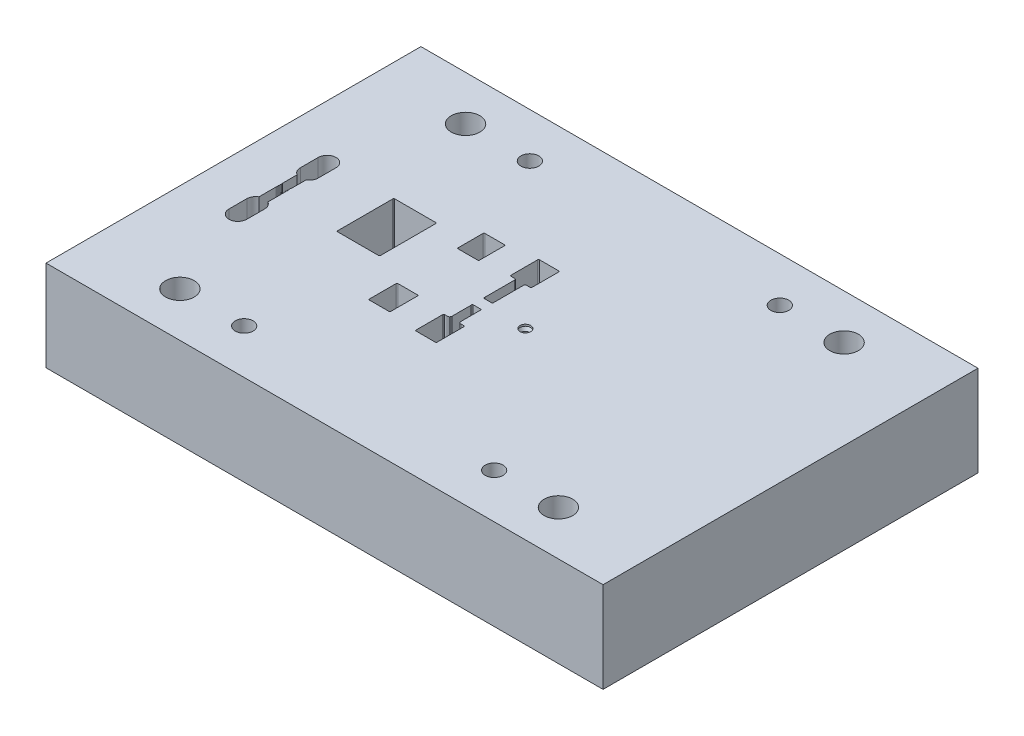
from build123d import *

# Parameters (mm, degrees)
SKETCH1_W             = 156
SKETCH1_H             = 25.4
EXTRUDE1_DEPTH        = 52.5
M6_TAPPED_HOLE1_D     = 5
M6_TAPPED_HOLE1_DEPTH = 15
M6_TAPPED_HOLE1_TIP   = 1.502151548
HOLE1_D               = 8
CUT_EXTRUDE1_DEPTH    = 26.4
CUT_EXTRUDE2_DEPTH    = 8
FILLET2_R             = 0.25
HOLE3_D               = 10
HOLE3_DEPTH           = 5


with BuildPart() as part:
    # Sketch1 → Extrude1 (new body, symmetric)
    with BuildSketch(Plane.XY):
        with Locations((0, 12.7)):
            Rectangle(SKETCH1_W, SKETCH1_H)
    extrude(amount=EXTRUDE1_DEPTH, both=True)

    # M6 Tapped Hole1
    with Locations(Plane(origin=(0, 25.4, 0), x_dir=(-1, 0, 0), z_dir=(0, 1, 0))):
        with Locations((35, -40), (-35, -40), (-35, 40), (35, 40)):
            Hole(M6_TAPPED_HOLE1_D / 2, depth=M6_TAPPED_HOLE1_DEPTH)
            with Locations((0, 0, -(M6_TAPPED_HOLE1_DEPTH + M6_TAPPED_HOLE1_TIP / 2))):  # 118° drill point
                Cone(0, M6_TAPPED_HOLE1_D / 2, M6_TAPPED_HOLE1_TIP, mode=Mode.SUBTRACT)

    # Hole1 (through all)
    with Locations(Plane(origin=(0, 25.4, 0), x_dir=(-1, 0, 0), z_dir=(0, 1, 0))):
        with Locations((53, -40), (53, 40), (-53, 40), (-53, -40)):
            Hole(HOLE1_D / 2)

    # Sketch6 → Cut-Extrude1 (cut, through all)
    with BuildSketch(Plane(origin=(0, 25.4, 0), x_dir=(1, 0, 0), z_dir=(0, 1, 0))):
        with BuildLine():
            Line((-61.75, -6.788439774), (-61.515076845, -7.433885839))
            ThreePointArc((-61.515076845, -7.433885839), (-61.545211989, -7.662784984), (-61.75, -7.769390874))
            Line((-61.75, -7.769390874), (-64.25, -7.769390874))
            ThreePointArc((-64.25, -7.769390874), (-64.454788011, -7.662784984), (-64.484923155, -7.433885839))
            Line((-64.484923155, -7.433885839), (-64.25, -6.788439774))
            Line((-64.25, -6.788439774), (-64.25, -1.795359581))
            ThreePointArc((-64.25, -1.795359581), (-64.237170825, -1.716302639), (-64.2, -1.645359581))
            ThreePointArc((-64.2, -1.645359581), (-64.15, -1.495359581), (-64.2, -1.345359581))
            ThreePointArc((-64.2, -1.345359581), (-64.25, -1.195359581), (-64.2, -1.045359581))
            ThreePointArc((-64.2, -1.045359581), (-64.15, -0.895359581), (-64.2, -0.745359581))
            ThreePointArc((-64.2, -0.745359581), (-64.25, -0.595359581), (-64.2, -0.445359581))
            ThreePointArc((-64.2, -0.445359581), (-64.15, -0.295359581), (-64.2, -0.145359581))
            ThreePointArc((-64.2, -0.145359581), (-64.237170825, -0.074416522), (-64.25, 0.004640419))
            Line((-64.25, 0.004640419), (-64.25, 4.249658026))
            Line((-64.25, 4.249658026), (-64.484923155, 4.89510409))
            ThreePointArc((-64.484923155, 4.89510409), (-64.454788011, 5.124003235), (-64.25, 5.230609126))
            Line((-64.25, 5.230609126), (-61.75, 5.230609126))
            ThreePointArc((-61.75, 5.230609126), (-61.545211989, 5.124003235), (-61.515076845, 4.89510409))
            Line((-61.515076845, 4.89510409), (-61.75, 4.249658026))
            Line((-61.75, 4.249658026), (-61.75, 0.004640419))
            ThreePointArc((-61.75, 0.004640419), (-61.762829175, -0.074416522), (-61.8, -0.145359581))
            ThreePointArc((-61.8, -0.145359581), (-61.85, -0.295359581), (-61.8, -0.445359581))
            ThreePointArc((-61.8, -0.445359581), (-61.75, -0.595359581), (-61.8, -0.745359581))
            ThreePointArc((-61.8, -0.745359581), (-61.85, -0.895359581), (-61.8, -1.045359581))
            ThreePointArc((-61.8, -1.045359581), (-61.75, -1.195359581), (-61.8, -1.345359581))
            ThreePointArc((-61.8, -1.345359581), (-61.85, -1.495359581), (-61.8, -1.645359581))
            ThreePointArc((-61.8, -1.645359581), (-61.762829175, -1.716302639), (-61.75, -1.795359581))
            Line((-61.75, -1.795359581), (-61.75, -6.788439774))
        make_face()
        with BuildLine():
            Line((-18.25, -8.195359581), (-23.75, -8.195359581))
            ThreePointArc((-23.75, -8.195359581), (-23.926776695, -8.268582886), (-24, -8.445359581))
            Line((-24, -8.445359581), (-24, -15.945359581))
            ThreePointArc((-24, -15.945359581), (-23.926776695, -16.122136276), (-23.75, -16.195359581))
            Line((-23.75, -16.195359581), (-18.25, -16.195359581))
            ThreePointArc((-18.25, -16.195359581), (-18.073223305, -16.122136276), (-18, -15.945359581))
            Line((-18, -15.945359581), (-18, -8.445359581))
            ThreePointArc((-18, -8.445359581), (-18.073223305, -8.268582886), (-18.25, -8.195359581))
        make_face()
        with BuildLine():
            Line((-18.25, 16.15), (-23.75, 16.15))
            ThreePointArc((-23.75, 16.15), (-23.926776695, 16.076776695), (-24, 15.9))
            Line((-24, 15.9), (-24, 8.9))
            ThreePointArc((-24, 8.9), (-23.926776695, 8.723223305), (-23.75, 8.65))
            Line((-23.75, 8.65), (-18.25, 8.65))
            ThreePointArc((-18.25, 8.65), (-18.073223305, 8.723223305), (-18, 8.9))
            Line((-18, 8.9), (-18, 15.9))
            ThreePointArc((-18, 15.9), (-18.073223305, 16.076776695), (-18.25, 16.15))
        make_face()
        with BuildLine():
            Line((-33, -3.845359581), (-33, 11.654640419))
            ThreePointArc((-33, 11.654640419), (-33.073223305, 11.831417114), (-33.25, 11.904640419))
            Line((-33.25, 11.904640419), (-44.75, 11.904640419))
            ThreePointArc((-44.75, 11.904640419), (-44.926776695, 11.831417114), (-45, 11.654640419))
            Line((-45, 11.654640419), (-45, -3.845359581))
            ThreePointArc((-45, -3.845359581), (-44.926776695, -4.022136276), (-44.75, -4.095359581))
            Line((-44.75, -4.095359581), (-33.25, -4.095359581))
            ThreePointArc((-33.25, -4.095359581), (-33.073223305, -4.022136276), (-33, -3.845359581))
        make_face()
        with BuildLine():
            Line((-9, -9.175359581), (-9.7, -9.175359581))
            ThreePointArc((-9.7, -9.175359581), (-9.876776695, -9.248582886), (-9.95, -9.425359581))
            Line((-9.95, -9.425359581), (-9.95, -16.925359581))
            ThreePointArc((-9.95, -16.925359581), (-9.876776695, -17.102136276), (-9.7, -17.175359581))
            Line((-9.7, -17.175359581), (-4.3, -17.175359581))
            ThreePointArc((-4.3, -17.175359581), (-4.123223305, -17.102136276), (-4.05, -16.925359581))
            Line((-4.05, -16.925359581), (-4.05, -9.425359581))
            ThreePointArc((-4.05, -9.425359581), (-4.123223305, -9.248582886), (-4.3, -9.175359581))
            Line((-4.3, -9.175359581), (-5, -9.175359581))
            ThreePointArc((-5, -9.175359581), (-5.24353124, -9.155458407), (-5.480600403, -9.096282961))
            ThreePointArc((-5.480600403, -9.096282961), (-5.506809725, -9.08528611), (-5.531195519, -9.070685003))
            ThreePointArc((-5.531195519, -9.070685003), (-5.577819834, -9.025074032), (-5.607289193, -8.966886884))
            Line((-5.607289193, -8.966886884), (-5.728461054, -8.582010558))
            ThreePointArc((-5.728461054, -8.582010558), (-5.737098425, -8.544913615), (-5.74, -8.506935091))
            Line((-5.74, -8.506935091), (-5.74, -3.270896942))
            ThreePointArc((-5.74, -3.270896942), (-5.736201938, -3.227484898), (-5.724923155, -3.185391906))
            Line((-5.724923155, -3.185391906), (-5.705076845, -3.130864617))
            ThreePointArc((-5.705076845, -3.130864617), (-5.735211989, -2.901965472), (-5.94, -2.795359581))
            Line((-5.94, -2.795359581), (-8.06, -2.795359581))
            ThreePointArc((-8.06, -2.795359581), (-8.264788011, -2.901965472), (-8.294923155, -3.130864617))
            Line((-8.294923155, -3.130864617), (-8.275076845, -3.185391906))
            ThreePointArc((-8.275076845, -3.185391906), (-8.263798062, -3.227484898), (-8.26, -3.270896942))
            Line((-8.26, -3.270896942), (-8.26, -8.506935091))
            ThreePointArc((-8.26, -8.506935091), (-8.262901575, -8.544913615), (-8.271538946, -8.582010558))
            Line((-8.271538946, -8.582010558), (-8.392710807, -8.966886884))
            ThreePointArc((-8.392710807, -8.966886884), (-8.422180166, -9.025074032), (-8.468804481, -9.070685003))
            ThreePointArc((-8.468804481, -9.070685003), (-8.493190275, -9.08528611), (-8.519399597, -9.096282961))
            ThreePointArc((-8.519399597, -9.096282961), (-8.75646876, -9.155458407), (-9, -9.175359581))
        make_face()
        with BuildLine():
            Line((-5.410610942, 9.4), (-4.3, 9.4))
            ThreePointArc((-4.3, 9.4), (-4.123223305, 9.473223305), (-4.05, 9.65))
            Line((-4.05, 9.65), (-4.05, 17.15))
            ThreePointArc((-4.05, 17.15), (-4.123223305, 17.326776695), (-4.3, 17.4))
            Line((-4.3, 17.4), (-9.7, 17.4))
            ThreePointArc((-9.7, 17.4), (-9.876776695, 17.326776695), (-9.95, 17.15))
            Line((-9.95, 17.15), (-9.95, 9.65))
            ThreePointArc((-9.95, 9.65), (-9.876776695, 9.473223305), (-9.7, 9.4))
            Line((-9.7, 9.4), (-8.589389058, 9.4))
            ThreePointArc((-8.589389058, 9.4), (-8.46961053, 9.369438156), (-8.379117223, 9.285224833))
            Line((-8.379117223, 9.285224833), (-8.299728165, 9.16177648))
            ThreePointArc((-8.299728165, 9.16177648), (-8.270137582, 9.097021645), (-8.26, 9.026551647))
            Line((-8.26, 9.026551647), (-8.26, 0.704640419))
            ThreePointArc((-8.26, 0.704640419), (-8.263798062, 0.661228375), (-8.275076845, 0.619135383))
            Line((-8.275076845, 0.619135383), (-8.284923155, 0.592082868))
            ThreePointArc((-8.284923155, 0.592082868), (-8.254788011, 0.363183723), (-8.05, 0.256577832))
            Line((-8.05, 0.256577832), (-5.95, 0.256577832))
            ThreePointArc((-5.95, 0.256577832), (-5.745211989, 0.363183723), (-5.715076845, 0.592082868))
            Line((-5.715076845, 0.592082868), (-5.724923155, 0.619135383))
            ThreePointArc((-5.724923155, 0.619135383), (-5.736201938, 0.661228375), (-5.74, 0.704640419))
            Line((-5.74, 0.704640419), (-5.74, 9.026551647))
            ThreePointArc((-5.74, 9.026551647), (-5.729862418, 9.097021645), (-5.700271835, 9.16177648))
            Line((-5.700271835, 9.16177648), (-5.620882777, 9.285224833))
            ThreePointArc((-5.620882777, 9.285224833), (-5.53038947, 9.369438156), (-5.410610942, 9.4))
        make_face()
    extrude(amount=-CUT_EXTRUDE1_DEPTH, mode=Mode.SUBTRACT)

    # Sketch7 → Cut-Extrude2 (cut)
    with BuildSketch(Plane(origin=(0, 25.4, 0), x_dir=(1, 0, 0), z_dir=(0, 1, 0))):
        with BuildLine():
            Line((-65.5, 6.230609126), (-65.5, 11.230609126))
            ThreePointArc((-65.5, 11.230609126), (-63, 13.730609126), (-60.5, 11.230609126))
            Line((-60.5, 11.230609126), (-60.5, 6.230609126))
            ThreePointArc((-60.5, 6.230609126), (-63, 3.730609126), (-65.5, 6.230609126))
        make_face()
        with BuildLine():
            Line((-60.5, -8.769390874), (-60.5, -13.769390874))
            ThreePointArc((-60.5, -13.769390874), (-63, -16.269390874), (-65.5, -13.769390874))
            Line((-65.5, -13.769390874), (-65.5, -8.769390874))
            ThreePointArc((-65.5, -8.769390874), (-63, -6.269390874), (-60.5, -8.769390874))
        make_face()
    extrude(amount=-CUT_EXTRUDE2_DEPTH, mode=Mode.SUBTRACT)

    # Fillet2
    fillet2_edges = [part.edges().sort_by_distance(p)[0] for p in [
        (-61.632538422, 17.4, 7.111162806),
        (-61.545211989, 17.4, 7.662784984),
        (-64.367461578, 17.4, 7.111162806),
        (-64.454788011, 17.4, 7.662784984),
        (-64.367461578, 17.4, -4.572381058),
        (-64.454788011, 17.4, -5.124003235),
        (-61.632538422, 17.4, -4.572381058),
        (-61.545211989, 17.4, -5.124003235),
        (-63, 17.4, 7.769390874),
        (-63, 17.4, -5.230609126),
    ]]
    fillet(fillet2_edges, radius=FILLET2_R)

    # Sketch8 → Hole2 (revolve, cut)
    with BuildSketch(Plane(origin=(5, 25.4, 1.269390874), x_dir=(0, 0, 1), z_dir=(1, 0, 0))):
        Polygon((0, 0), (0, 100), (1, 100), (1, 1.366025404), (1.5, 0.5), (1.5, 0), align=None)
    revolve(axis=Axis((5, 31.530023899, 1.269390874), (0, -1, 0)), mode=Mode.SUBTRACT)

    # Hole3
    with Locations(Plane(origin=(0, 0, 0), x_dir=(-1, 0, 0), z_dir=(0, -1, 0))):
        with Locations((42, -16)):
            Hole(HOLE3_D / 2, depth=HOLE3_DEPTH)


solid = part.part
